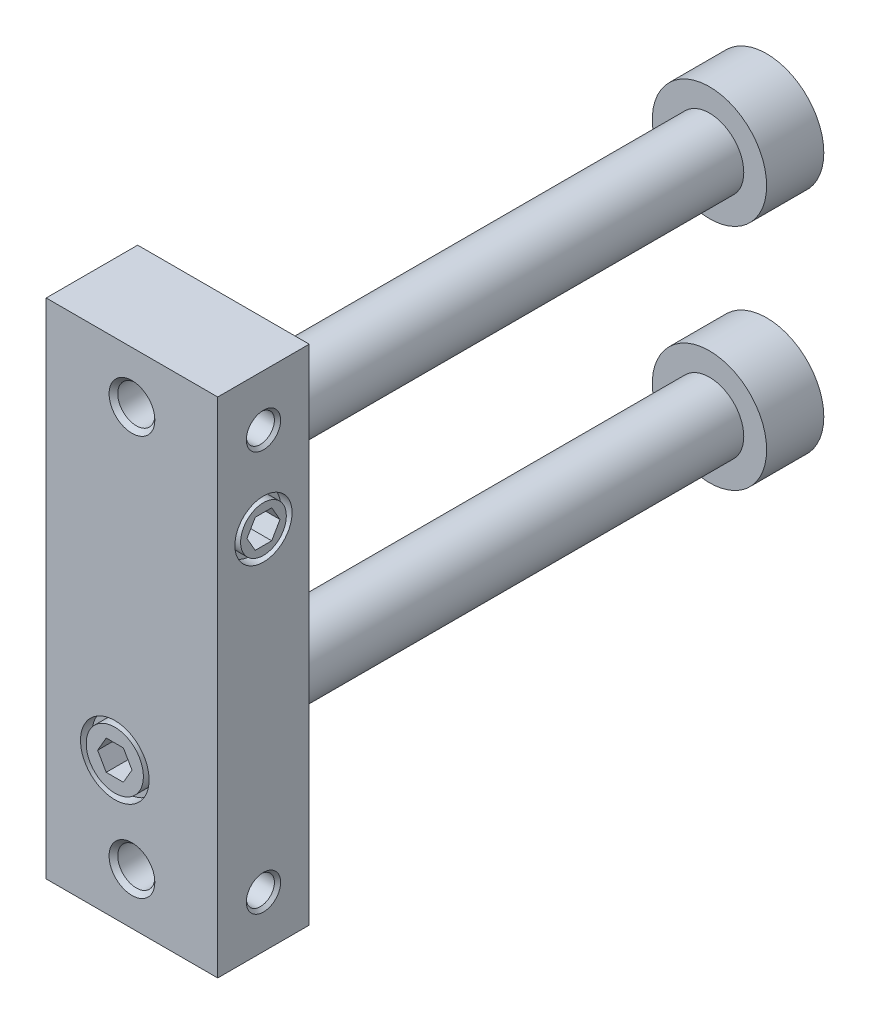
from build123d import *

# Parameters (mm, degrees)
SKETCH_1_W          = 15
SKETCH_1_H          = 44
EXTRUDE_1_DEPTH     = 8
CUT_EXTRUDE_START   = -1
SKETCH_10_R         = 3
SKETCH_10_R_2       = 2.5
CUT_EXTRUDE_1_DEPTH = 1
CUT_EXTRUDE_2_DEPTH = 2.6
SKETCH_12_R         = 2.5
SKETCH_12_R_2       = 2
CUT_EXTRUDE_3_DEPTH = 1
CUT_EXTRUDE_4_DEPTH = 2.5


with BuildPart() as part:
    # 草图1 → 凸台-拉伸1 (new body)
    with BuildSketch(Plane.XY.offset(9)):
        with Locations((1.5, 0)):
            Rectangle(SKETCH_1_W, SKETCH_1_H)
    extrude(amount=EXTRUDE_1_DEPTH)

    # 草图2 → 旋转1 (revolve)
    with BuildSketch(Plane(origin=(0, 0, 0), x_dir=(0, 0, -1), z_dir=(1, 0, 0))):
        Polygon((-14, 10), (-14, 13), (35, 13), (35, 15), (40, 15), (40, 10), align=None)
    revolve(axis=Axis((0, 10, -40), (0, 0, 1)))

    # 草图3 → 旋转2 (revolve)
    with BuildSketch(Plane(origin=(0, 0, 0), x_dir=(0, 0, -1), z_dir=(1, 0, 0))):
        Polygon((-14, -10), (-14, -7), (35, -7), (35, -5), (40, -5), (40, -10), align=None)
    revolve(axis=Axis((0, -10, -40), (0, 0, 1)))

    # 草图4 → 切除-旋转1 (revolve, cut)
    with BuildSketch(Plane(origin=(1.5, 0, 0), x_dir=(0, 0, -1), z_dir=(1, 0, 0))):
        Polygon((-17, 17.5), (-17, 19.5), (-16.621, 19.121), (-9.379, 19.121), (-9, 19.5), (-9, 17.5), align=None)
    revolve(axis=Axis((1.5, 17.5, 9), (0, 0, 1)), mode=Mode.SUBTRACT)

    # 草图5 → 切除-旋转2 (revolve, cut)
    with BuildSketch(Plane(origin=(1.5, 0, 0), x_dir=(0, 0, -1), z_dir=(1, 0, 0))):
        Polygon((-17, -17.5), (-17, -15.5), (-16.621, -15.879), (-9.379, -15.879), (-9, -15.5), (-9, -17.5), align=None)
    revolve(axis=Axis((1.5, -17.5, 9), (0, 0, 1)), mode=Mode.SUBTRACT)

    # 草图6 → 切除-旋转3 (revolve, cut)
    with BuildSketch(Plane.XY.offset(13)):
        Polygon((-6, 17.5), (-6, 19), (-5.7295, 18.7295), (-1, 18.7295), (-0.290147844, 17.5), align=None)
    revolve(axis=Axis((-0.290147844, 17.5, 13), (-1, 0, 0)), mode=Mode.SUBTRACT)

    # 草图7 → 切除-旋转4 (revolve, cut)
    with BuildSketch(Plane.XY.offset(13)):
        Polygon((-0.290147844, -17.5), (-1, -18.7295), (-5.7295, -18.7295), (-6, -19), (-6, -17.5), align=None)
    revolve(axis=Axis((-6, -17.5, 13), (1, 0, 0)), mode=Mode.SUBTRACT)

    # 草图8 → 切除-旋转5 (revolve, cut)
    with BuildSketch(Plane.XY.offset(13)):
        Polygon((3.290147844, 17.5), (4, 18.7295), (8.7295, 18.7295), (9, 19), (9, 17.5), align=None)
    revolve(axis=Axis((9, 17.5, 13), (-1, 0, 0)), mode=Mode.SUBTRACT)

    # 草图9 → 切除-旋转6 (revolve, cut)
    with BuildSketch(Plane.XY.offset(13)):
        Polygon((9, -17.5), (9, -19), (8.7295, -18.7295), (4, -18.7295), (3.290147844, -17.5), align=None)
    revolve(axis=Axis((3.290147844, -17.5, 13), (1, 0, 0)), mode=Mode.SUBTRACT)

    # 草图10 → 切除-拉伸1 (cut)
    with BuildSketch(Plane.XY.offset(17).offset(CUT_EXTRUDE_START)):
        with Locations((0, -10)):
            Circle(SKETCH_10_R)
        with Locations((0, -10)):
            Circle(SKETCH_10_R_2, mode=Mode.SUBTRACT)
    extrude(amount=CUT_EXTRUDE_1_DEPTH, mode=Mode.SUBTRACT)

    # 草图11 → 切除-拉伸2 (cut)
    with BuildSketch(Plane.XY.offset(17)):
        Polygon((-1.5011107, -10), (-0.75055535, -11.3), (0.75055535, -11.3), (1.5011107, -10), (0.75055535, -8.7), (-0.75055535, -8.7), align=None)
    extrude(amount=-CUT_EXTRUDE_2_DEPTH, mode=Mode.SUBTRACT)

    # 草图12 → 切除-拉伸3 (cut)
    with BuildSketch(Plane(origin=(9, 0, 0), x_dir=(0, 0, -1), z_dir=(1, 0, 0))):
        with Locations((-13, 10)):
            Circle(SKETCH_12_R)
        with Locations((-13, 10)):
            Circle(SKETCH_12_R_2, mode=Mode.SUBTRACT)
    extrude(amount=-CUT_EXTRUDE_3_DEPTH, mode=Mode.SUBTRACT)

    # 草图13 → 切除-拉伸4 (cut)
    with BuildSketch(Plane(origin=(9, 0, 0), x_dir=(0, 0, -1), z_dir=(1, 0, 0))):
        Polygon((-14.443375673, 10), (-13.721687836, 8.75), (-12.278312164, 8.75), (-11.556624327, 10), (-12.278312164, 11.25), (-13.721687836, 11.25), align=None)
    extrude(amount=-CUT_EXTRUDE_4_DEPTH, mode=Mode.SUBTRACT)


solid = part.part
